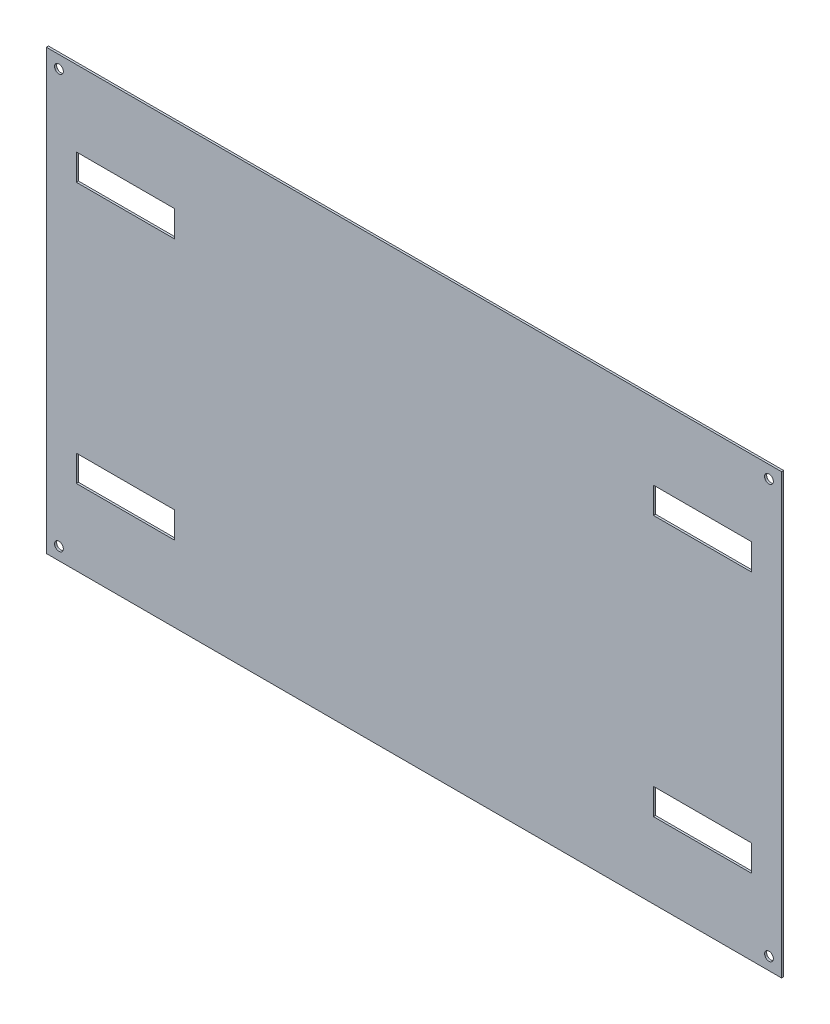
from build123d import *

# Parameters (mm, degrees)
SKETCH1_W               = 840
SKETCH1_H               = 501
SKETCH1_R               = 5
BOSS_EXTRUDE1_DEPTH     = 2.4
SKETCH2_W               = 112
SKETCH2_H               = 30
CUT_EXTRUDE1_DEPTH      = 34
MIRROR2_COPY_1_SKETCH_W = 112
MIRROR2_COPY_1_SKETCH_H = 30
MIRROR2_COPY_1_DEPTH    = 34


with BuildPart() as part:
    # Sketch1 → Boss-Extrude1 (new body)
    with BuildSketch(Plane.XY):
        with Locations((420, 250.5)):
            Rectangle(SKETCH1_W, SKETCH1_H)
        with Locations((825.625, 486.625)):
            Circle(SKETCH1_R, mode=Mode.SUBTRACT)
        with Locations((14.375, 14.375)):
            Circle(SKETCH1_R, mode=Mode.SUBTRACT)
        with Locations((14.375, 486.625)):
            Circle(SKETCH1_R, mode=Mode.SUBTRACT)
        with Locations((825.625, 14.375)):
            Circle(SKETCH1_R, mode=Mode.SUBTRACT)
    extrude(amount=BOSS_EXTRUDE1_DEPTH)

    # Sketch2 → Cut-Extrude1 (cut)
    with BuildSketch(Plane.XY.offset(2.4)):
        with Locations((90.32, 101.47)):
            Rectangle(SKETCH2_W, SKETCH2_H)
    cut_extrude1 = extrude(amount=-CUT_EXTRUDE1_DEPTH, mode=Mode.SUBTRACT)

    # Mirror1: Cut-Extrude1 across plane
    add(cut_extrude1.mirror(Plane(origin=(420, 0, 0), x_dir=(0, 0, 1), z_dir=(1, 0, 0))), mode=Mode.SUBTRACT)

    # Mirror2: Cut-Extrude1 across plane
    add(cut_extrude1.mirror(Plane(origin=(0, 250.5, 0), x_dir=(0, 0, 1), z_dir=(0, -1, 0))), mode=Mode.SUBTRACT)

    # Mirror2 copy 1 sketch → Mirror2 copy 1 (cut)
    with BuildSketch(Plane(origin=(840, 501, 2.4), x_dir=(-1, 0, 0), z_dir=(0, 0, 1))):
        with Locations((90.32, 101.47)):
            Rectangle(MIRROR2_COPY_1_SKETCH_W, MIRROR2_COPY_1_SKETCH_H)
    extrude(amount=-MIRROR2_COPY_1_DEPTH, mode=Mode.SUBTRACT)


solid = part.part
